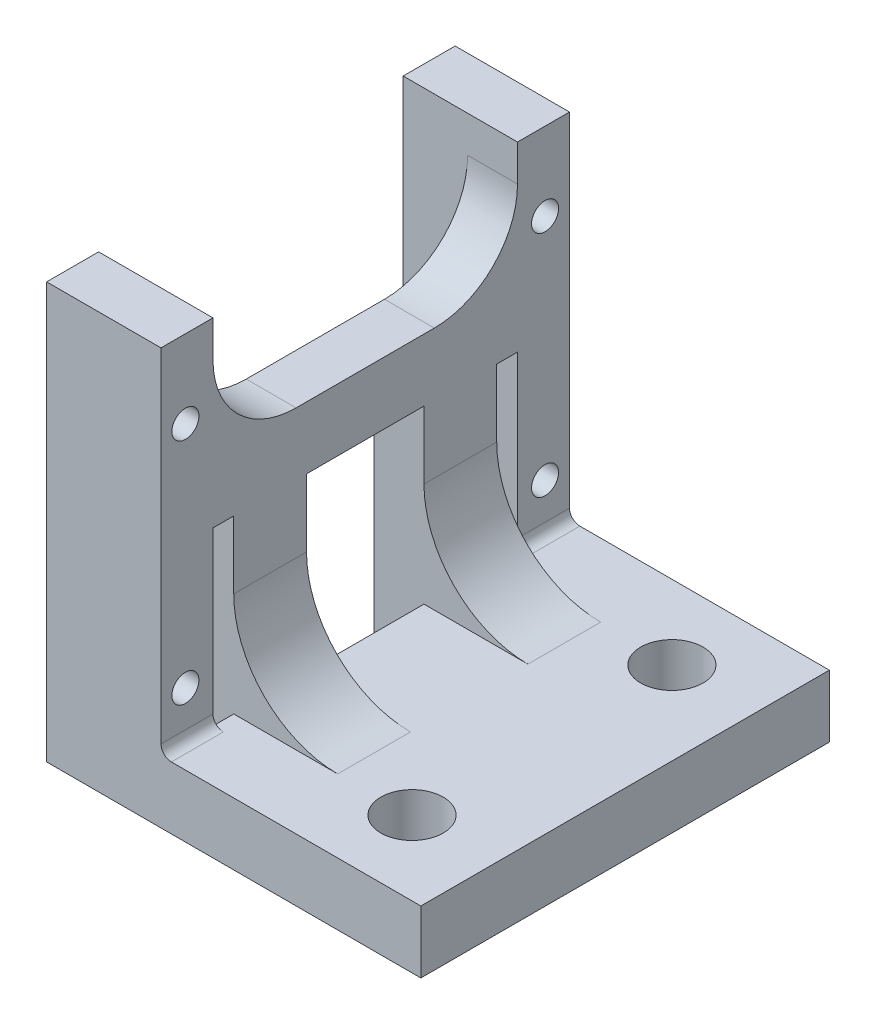
from build123d import *

# Parameters (mm, degrees)
SKETCH1_W             = 5
SKETCH1_H             = 40
SKETCH1_R             = 1.3
BOSS_EXTRUDE1_DEPTH   = 11
BOSS_EXTRUDE1_2_DEPTH = 11
SKETCH2_W             = 39.3
SKETCH2_H             = 6
BOSS_EXTRUDE2_DEPTH   = 25
BOSS_EXTRUDE3_DEPTH   = 4.8
FILLET1_R             = 1
SKETCH4_R             = 3
CUT_EXTRUDE1_DEPTH    = 34
FILLET2_R             = 10
FILLET3_R             = 8


with BuildPart() as part:
    # Sketch1 → Boss-Extrude1 (new body)
    with BuildSketch(Plane(origin=(0, 0, 0), x_dir=(0, 0, -1), z_dir=(1, 0, 0))):
        with Locations((-17.15, 20)):
            Rectangle(SKETCH1_W, SKETCH1_H)
        with Locations((-17.3, 32.5)):
            Circle(SKETCH1_R, mode=Mode.SUBTRACT)
        with Locations((-17.3, 10.5)):
            Circle(SKETCH1_R, mode=Mode.SUBTRACT)
    extrude(amount=BOSS_EXTRUDE1_DEPTH)



with BuildPart() as body_2:
    # Sketch1 → Boss-Extrude1 2 (new body)
    with BuildSketch(Plane(origin=(0, 0, 0), x_dir=(0, 0, -1), z_dir=(1, 0, 0))):
        with Locations((17.15, 20)):
            Rectangle(SKETCH1_W, SKETCH1_H)
        with Locations((17.3, 10.5)):
            Circle(SKETCH1_R, mode=Mode.SUBTRACT)
        with Locations((17.3, 32.5)):
            Circle(SKETCH1_R, mode=Mode.SUBTRACT)
    extrude(amount=BOSS_EXTRUDE1_2_DEPTH)


with BuildPart() as part_1:
    add(part.part)

    add(body_2.part)  # Boss-Extrude2 merges body 2
    # Sketch2 → Boss-Extrude2 (add)
    with BuildSketch(Plane(origin=(11, 0, 0), x_dir=(0, 0, -1), z_dir=(1, 0, 0))):
        with Locations((0, 3)):
            Rectangle(SKETCH2_W, SKETCH2_H)
    extrude(amount=BOSS_EXTRUDE2_DEPTH)

    # Sketch3 → Boss-Extrude3 (add)
    with BuildSketch(Plane(origin=(11, 0, 0), x_dir=(0, 0, -1), z_dir=(1, 0, 0))):
        Polygon((-14.65, 22.5), (-12.65, 22.5), (-12.65, 0), (-5.65, 0), (-5.65, 22.5), (5.65, 22.5), (5.65, 0), (12.65, 0), (12.65, 22.5), (14.65, 22.5), (14.65, 28.5), (-14.65, 28.5), align=None)
    extrude(amount=-BOSS_EXTRUDE3_DEPTH)

    # Fillet1
    fillet1_edges = [part_1.edges().sort_by_distance(p)[0] for p in [
        (11, 6, 17.15),
        (11, 6, -17.15),
    ]]
    fillet(fillet1_edges, radius=FILLET1_R)

    # Sketch4 → Cut-Extrude1 (cut)
    with BuildSketch(Plane(origin=(0, 6, 0), x_dir=(1, 0, 0), z_dir=(0, 1, 0))):
        with Locations((28, 12.5)):
            Circle(SKETCH4_R)
        with Locations((28, -12.5)):
            Circle(SKETCH4_R)
    extrude(amount=-CUT_EXTRUDE1_DEPTH, mode=Mode.SUBTRACT)

    # Fillet2
    fillet2_edges = [part_1.edges().sort_by_distance(p)[0] for p in [
        (11, 6, 9.15),
        (11, 6, -9.15),
    ]]
    fillet(fillet2_edges, radius=FILLET2_R)

    # Fillet3
    fillet3_edges = [part_1.edges().sort_by_distance(p)[0] for p in [
        (8.6, 28.5, 14.65),
        (8.6, 28.5, -14.65),
    ]]
    fillet(fillet3_edges, radius=FILLET3_R)


solid = part_1.part
